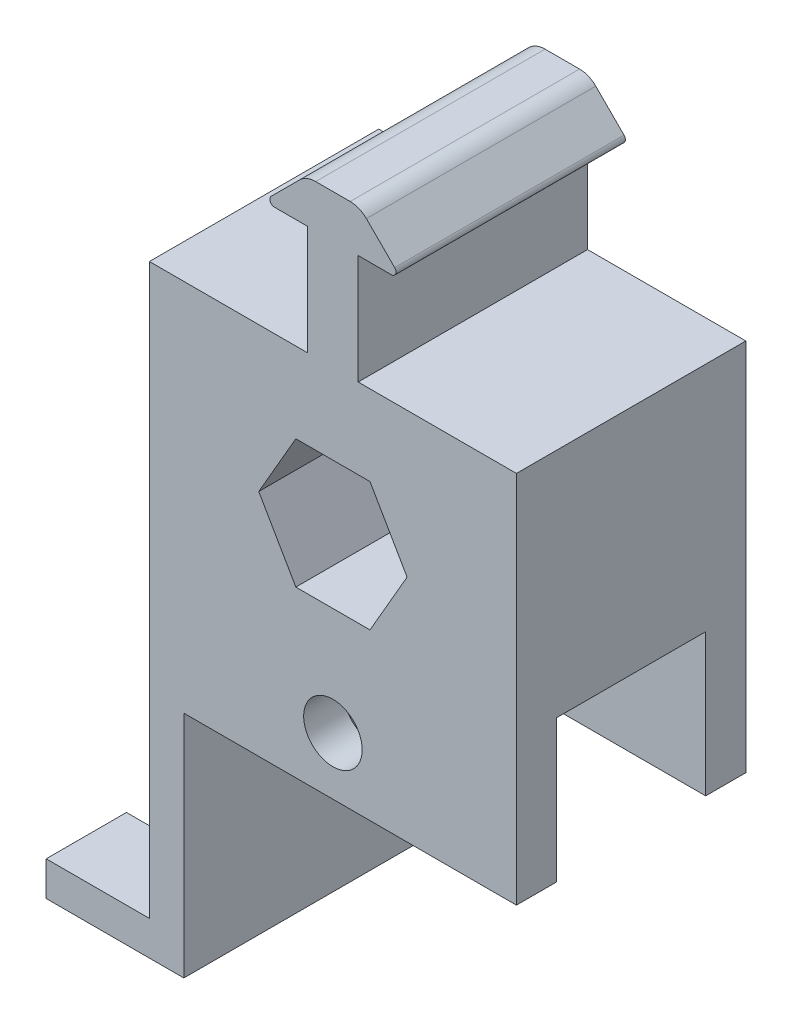
from build123d import *

# Parameters (mm, degrees)
BOSS_EXTRUDE1_DEPTH             = 12.7
BOSS_EXTRUDE4_REACH             = 14.7
BOSS_EXTRUDE4_DIRECTION_2_REACH = 14.7
SKETCH6_W                       = 16.51
SKETCH6_H                       = 15.748
CUT_EXTRUDE2_DEPTH              = 53.07
SKETCH11_W                      = 11.43
SKETCH11_H                      = 7.62
CUT_EXTRUDE3_DEPTH              = 3.81
SKETCH15_R                      = 3.2385
CUT_EXTRUDE4_DEPTH              = 25.4


with BuildPart() as part:
    # Sketch1 → Boss-Extrude1 (new body, symmetric)
    with BuildSketch(Plane.XY):
        with BuildLine():
            Line((-20.32, 16.002), (-20.32, -25.4))
            Line((-20.32, -25.4), (20.32, -25.4))
            Line((20.32, -25.4), (20.32, 16.002))
            Line((20.32, 16.002), (2.794, 16.002))
            Line((2.794, 16.002), (2.794, 28.1305))
            Line((2.794, 28.1305), (6.477, 28.1305))
            ThreePointArc((6.477, 28.1305), (6.946330803, 28.444096816), (6.836210245, 28.997710245))
            Line((6.836210245, 28.997710245), (3.706459265, 32.127461224))
            ThreePointArc((3.706459265, 32.127461224), (2.882423959, 32.678064013), (1.910408041, 32.87141))
            Line((1.910408041, 32.87141), (-1.910408041, 32.87141))
            ThreePointArc((-1.910408041, 32.87141), (-2.882423959, 32.678064013), (-3.706459265, 32.127461224))
            Line((-3.706459265, 32.127461224), (-6.836210245, 28.997710245))
            ThreePointArc((-6.836210245, 28.997710245), (-6.946330803, 28.444096816), (-6.477, 28.1305))
            Line((-6.477, 28.1305), (-2.794, 28.1305))
            Line((-2.794, 28.1305), (-2.794, 16.002))
            Line((-2.794, 16.002), (-20.32, 16.002))
        make_face()
        Polygon((-4.106115114, 7.112), (-8.212230229, 0), (-4.106115114, -7.112), (4.106115114, -7.112), (8.212230229, 0), (4.106115114, 7.112), align=None, mode=Mode.SUBTRACT)
    extrude(amount=BOSS_EXTRUDE1_DEPTH, both=True)

    # Boss-Extrude4: up to this face of the body (flat: up to its plane)
    boss_extrude4_end = Plane(part.part.faces().sort_by_distance((-6.289975232, 28.715968196, 12.7))[0])
    # Sketch10 → Boss-Extrude4 (add, up to the picked face)
    with BuildSketch(Plane.XY, mode=Mode.PRIVATE) as boss_extrude4_sk1:
        Polygon((-20.32, -25.4), (-20.32, -46.99), (-31.75, -46.99), (-31.75, -50.8), (-16.51, -50.8), (-16.51, -25.4), align=None)
    boss_extrude4_tool1 = split(extrude(boss_extrude4_sk1.sketch, amount=BOSS_EXTRUDE4_REACH, mode=Mode.PRIVATE), bisect_by=boss_extrude4_end, keep=Keep.BOTH, mode=Mode.PRIVATE)
    add(boss_extrude4_tool1.solids().sort_by_distance((-20.023788, -36.195, 0))[0])

    # Boss-Extrude4 direction 2: up to this face of the body (flat: up to its plane)
    boss_extrude4_direction_2_end = Plane(part.part.faces().sort_by_distance((-6.289975232, 28.715968196, -12.7))[0])
    # Sketch10 → Boss-Extrude4 direction 2 (add, up to the picked face)
    with BuildSketch(Plane.XY, mode=Mode.PRIVATE) as boss_extrude4_direction_2_sk1:
        Polygon((-20.32, -25.4), (-20.32, -46.99), (-31.75, -46.99), (-31.75, -50.8), (-16.51, -50.8), (-16.51, -25.4), align=None)
    boss_extrude4_direction_2_tool1 = split(extrude(boss_extrude4_direction_2_sk1.sketch, amount=-BOSS_EXTRUDE4_DIRECTION_2_REACH, mode=Mode.PRIVATE), bisect_by=boss_extrude4_direction_2_end, keep=Keep.BOTH, mode=Mode.PRIVATE)
    add(boss_extrude4_direction_2_tool1.solids().sort_by_distance((-20.023788, -36.195, 0))[0])

    # Sketch6 → Cut-Extrude2 (cut, through all)
    with BuildSketch(Plane(origin=(20.32, 0, 0), x_dir=(0, 0, -1), z_dir=(1, 0, 0))):
        with Locations((0, -17.526)):
            Rectangle(SKETCH6_W, SKETCH6_H)
    extrude(amount=-CUT_EXTRUDE2_DEPTH, mode=Mode.SUBTRACT)

    # Sketch11 → Cut-Extrude3 (cut)
    with BuildSketch(Plane(origin=(0, -46.99, 0), x_dir=(1, 0, 0), z_dir=(0, 1, 0))):
        with Locations((-26.035, 0)):
            Rectangle(SKETCH11_W, SKETCH11_H)
    extrude(amount=-CUT_EXTRUDE3_DEPTH, mode=Mode.SUBTRACT)

    # Sketch15 → Cut-Extrude4 (cut)
    with BuildSketch(Plane.XY.offset(12.7)):
        with Locations((0, -19.05)):
            Circle(SKETCH15_R)
    extrude(amount=-CUT_EXTRUDE4_DEPTH, mode=Mode.SUBTRACT)


solid = part.part
